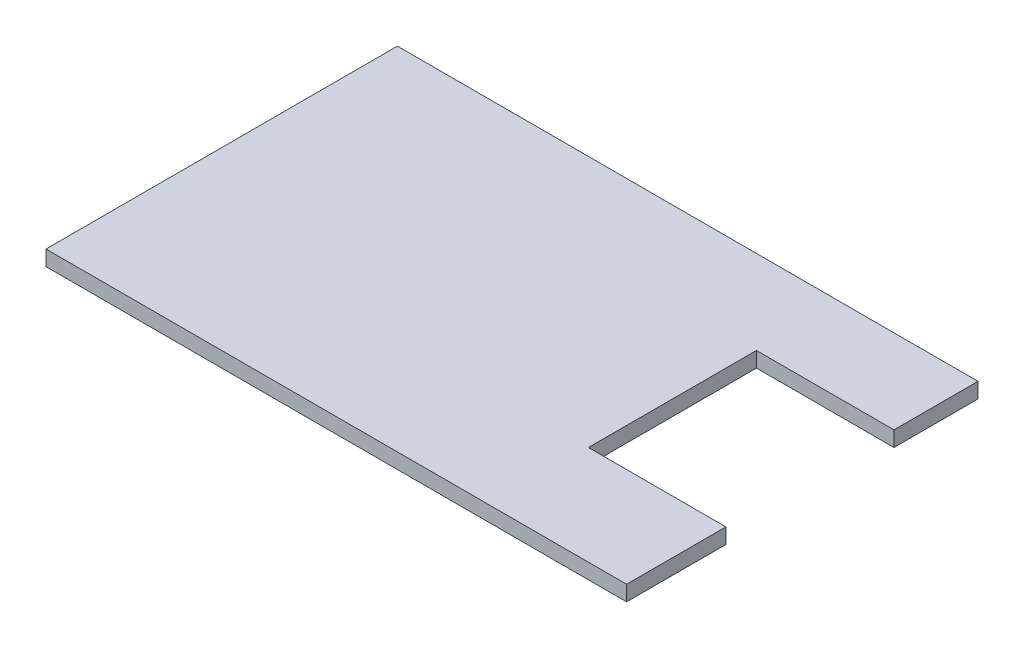
from build123d import *

# Parameters (mm, degrees)
BOSS_EXTRUDE1_DEPTH = 2


with BuildPart() as part:
    # Sketch1 → Boss-Extrude1 (new body)
    with BuildSketch(Plane(origin=(0, 0, 0), x_dir=(1, 0, 0), z_dir=(0, 1, 0))):
        Polygon((76, 35), (76, 46), (0, 46), (0, 0), (76, 0), (76, 13), (58, 13), (58, 35), align=None)
    extrude(amount=BOSS_EXTRUDE1_DEPTH)


solid = part.part
